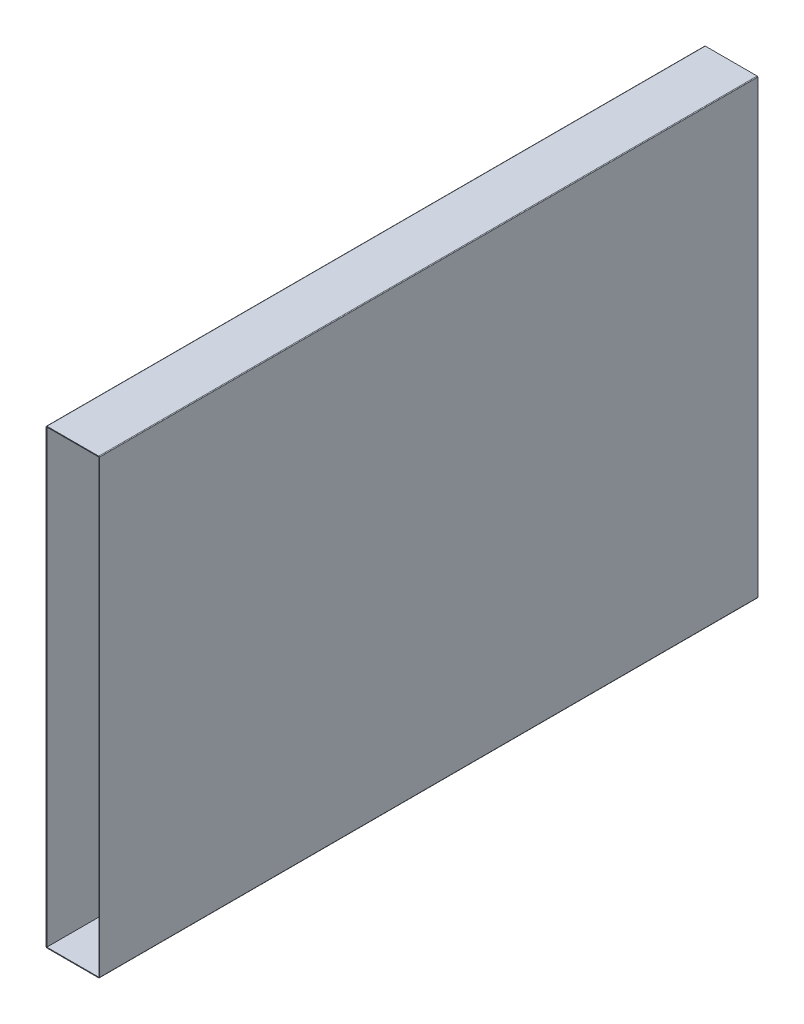
from build123d import *

# Parameters (mm, degrees)
ESQUISSE1_W        = 15
ESQUISSE1_H        = 130
BOSS_EXTRU_1_DEPTH = 190


with BuildPart() as part:
    # Esquisse1 → Boss.-Extru.1 (new body)
    with BuildSketch(Plane.XY):
        with BuildLine():
            Line((182.536477112, -69.556716073), (197.463522888, -69.556716073))
            ThreePointArc((197.463522888, -69.556716073), (197.604944244, -69.498137429), (197.663522888, -69.356716073))
            Line((197.663522888, -69.356716073), (197.663522888, 60.646093627))
            ThreePointArc((197.663522888, 60.646093627), (197.604944244, 60.787514983), (197.463522888, 60.846093627))
            Line((197.463522888, 60.846093627), (182.536477112, 60.846093627))
            ThreePointArc((182.536477112, 60.846093627), (182.395055756, 60.787514983), (182.336477112, 60.646093627))
            Line((182.336477112, 60.646093627), (182.336477112, -69.356716073))
            ThreePointArc((182.336477112, -69.356716073), (182.395055756, -69.498137429), (182.536477112, -69.556716073))
        make_face()
        with Locations((190, -4.355311223)):
            Rectangle(ESQUISSE1_W, ESQUISSE1_H, mode=Mode.SUBTRACT)
    extrude(amount=BOSS_EXTRU_1_DEPTH)


solid = part.part
